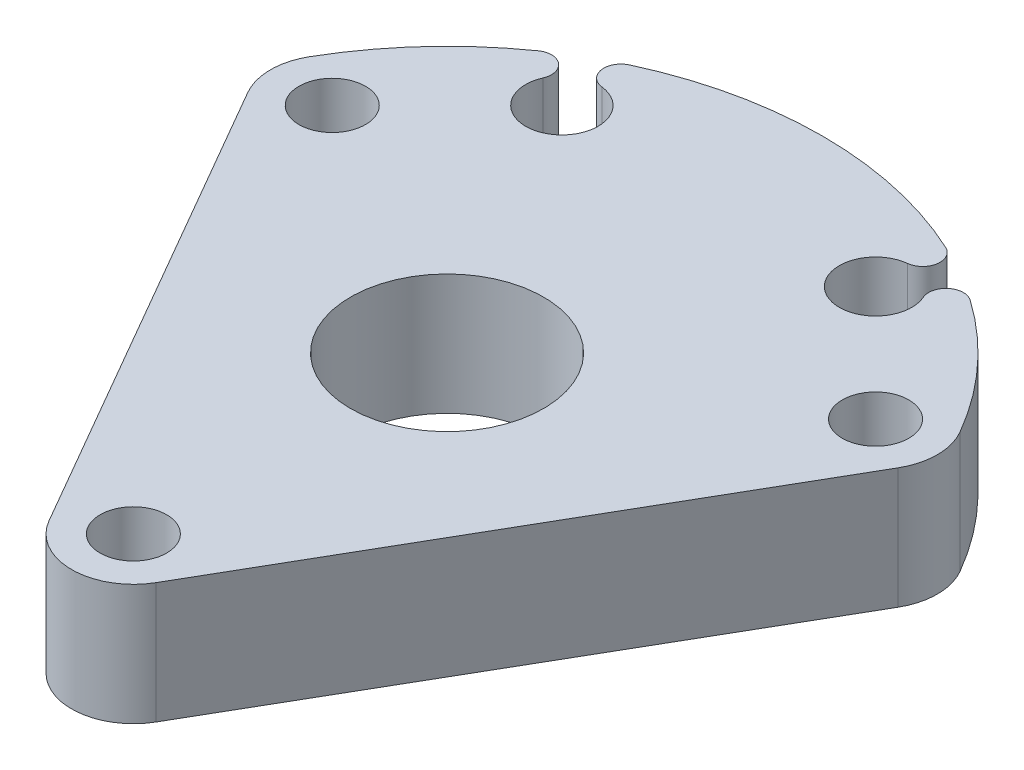
from build123d import *

# Parameters (mm, degrees)
SKETCH1_R           = 5.08
SKETCH1_R_2         = 1.75
BOSS_EXTRUDE1_DEPTH = 6.35
CUT_EXTRUDE1_DEPTH  = 7.35
CIRPATTERN1_COUNT   = 2
CIRPATTERN1_ANGLE   = 60


with BuildPart() as part:
    # Sketch1 → Boss-Extrude1 (new body)
    with BuildSketch(Plane(origin=(0, 0, 0), x_dir=(1, 0, 0), z_dir=(0, 1, 0))):
        with BuildLine():
            Line((-17.104001725, 6.625), (-2.814582562, -18.125))
            ThreePointArc((-2.814582562, -18.125), (0, -19.75), (2.814582562, -18.125))
            Line((2.814582562, -18.125), (17.104001725, 6.625))
            ThreePointArc((17.104001725, 6.625), (17.539419162, 8.25), (17.104001725, 9.875))
            ThreePointArc((17.104001725, 9.875), (0, 19.75), (-17.104001725, 9.875))
            ThreePointArc((-17.104001725, 9.875), (-17.539419162, 8.25), (-17.104001725, 6.625))
        make_face()
        Circle(SKETCH1_R, mode=Mode.SUBTRACT)
        with Locations((-14.289419162, 8.25)):
            Circle(SKETCH1_R_2, mode=Mode.SUBTRACT)
        with Locations((0, -16.5)):
            Circle(SKETCH1_R_2, mode=Mode.SUBTRACT)
        with Locations((14.289419162, 8.25)):
            Circle(SKETCH1_R_2, mode=Mode.SUBTRACT)
    extrude(amount=BOSS_EXTRUDE1_DEPTH)

    # Sketch2 → Cut-Extrude1 (cut, through all)
    with BuildSketch(Plane(origin=(0, 6.35, 0), x_dir=(1, 0, 0), z_dir=(0, 1, 0))):
        with BuildLine():
            ThreePointArc((8.036161973, 16.182379357), (7.2975, 12.639640768), (9.99627063, 15.050710096))
            ThreePointArc((9.99627063, 15.050710096), (10.255103275, 16.120005739), (11.354562521, 16.159715652))
            ThreePointArc((11.354562521, 16.159715652), (9.875, 17.104001725), (8.317443012, 17.913197418))
            ThreePointArc((8.317443012, 17.913197418), (8.832782842, 16.941182824), (8.036161973, 16.182379357))
        make_face()
    cut_extrude1 = extrude(amount=-CUT_EXTRUDE1_DEPTH, mode=Mode.SUBTRACT)

    # CirPattern1: Cut-Extrude1 ×2 about axis
    cirpattern1_axis = Axis((0, 0, 0), (0, 1, 0))
    for i in range(1, CIRPATTERN1_COUNT):
        add(cut_extrude1.rotate(cirpattern1_axis, i * CIRPATTERN1_ANGLE / (CIRPATTERN1_COUNT - 1)), mode=Mode.SUBTRACT)


solid = part.part
